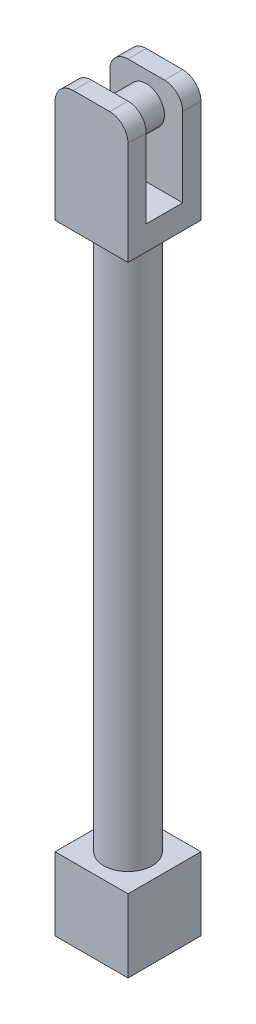
from build123d import *

# Parameters (mm, degrees)
SKETCH1_W           = 30
SKETCH1_H           = 30
BOSS_EXTRUDE1_DEPTH = 30
SKETCH2_R           = 10
BOSS_EXTRUDE2_DEPTH = 225
SKETCH3_W           = 30
SKETCH3_H           = 30
BOSS_EXTRUDE3_DEPTH = 50
SKETCH4_W           = 30
SKETCH4_H           = 15
CUT_EXTRUDE1_DEPTH  = 40
SKETCH5_R           = 7.5
BOSS_EXTRUDE4_DEPTH = 15
FILLET1_R           = 7.5


with BuildPart() as part:
    # Sketch1 → Boss-Extrude1 (new body)
    with BuildSketch(Plane(origin=(0, 0, 0), x_dir=(1, 0, 0), z_dir=(0, 1, 0))):
        Rectangle(SKETCH1_W, SKETCH1_H)
    extrude(amount=BOSS_EXTRUDE1_DEPTH)

    # Sketch2 → Boss-Extrude2 (add)
    with BuildSketch(Plane(origin=(0, 30, 0), x_dir=(1, 0, 0), z_dir=(0, 1, 0))):
        Circle(SKETCH2_R)
    extrude(amount=BOSS_EXTRUDE2_DEPTH)

    # Sketch3 → Boss-Extrude3 (add)
    with BuildSketch(Plane(origin=(0, 255, 0), x_dir=(1, 0, 0), z_dir=(0, 1, 0))):
        Rectangle(SKETCH3_W, SKETCH3_H)
    extrude(amount=BOSS_EXTRUDE3_DEPTH)

    # Sketch4 → Cut-Extrude1 (cut)
    with BuildSketch(Plane(origin=(0, 305, 0), x_dir=(1, 0, 0), z_dir=(0, 1, 0))):
        Rectangle(SKETCH4_W, SKETCH4_H)
    extrude(amount=-CUT_EXTRUDE1_DEPTH, mode=Mode.SUBTRACT)

    # Sketch5 → Boss-Extrude4 (add)
    with BuildSketch(Plane(origin=(0, 0, 7.5), x_dir=(-1, 0, 0), z_dir=(0, 0, -1))):
        with Locations((0, 292.5)):
            Circle(SKETCH5_R)
    extrude(amount=BOSS_EXTRUDE4_DEPTH)

    # Fillet1
    fillet1_edges = [part.edges().sort_by_distance(p)[0] for p in [
        (15, 305, 11.25),
        (-15, 305, -11.25),
        (15, 305, -11.25),
        (-15, 305, 11.25),
    ]]
    fillet(fillet1_edges, radius=FILLET1_R)


solid = part.part
